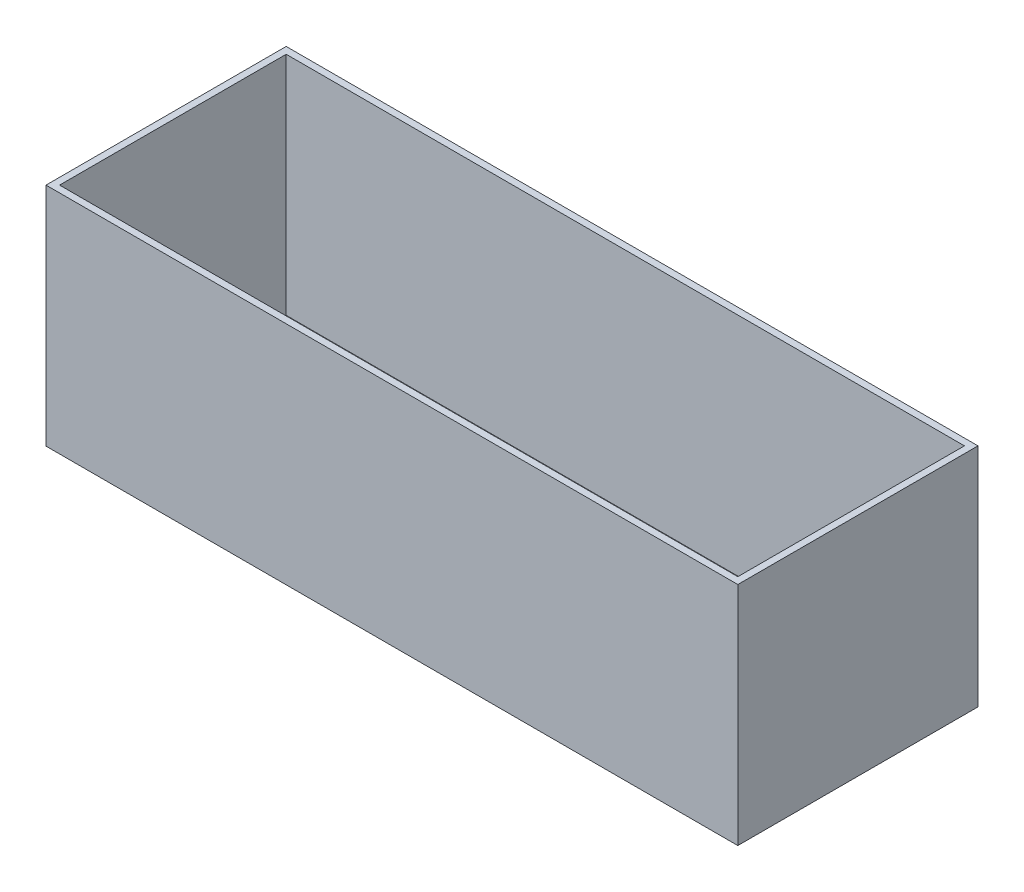
from build123d import *

# Parameters (mm, degrees)
SKETCH2_W           = 306
SKETCH2_H           = 106.24
SKETCH2_W_2         = 300
SKETCH2_H_2         = 100.24
BOSS_EXTRUDE1_DEPTH = 100


with BuildPart() as part:
    # Sketch2 → Boss-Extrude1 (new body)
    with BuildSketch(Plane(origin=(0, 0, 0), x_dir=(1, 0, 0), z_dir=(0, 1, 0))):
        with Locations((150, 50.12)):
            Rectangle(SKETCH2_W, SKETCH2_H)
        with Locations((150, 50.12)):
            Rectangle(SKETCH2_W_2, SKETCH2_H_2, mode=Mode.SUBTRACT)
    extrude(amount=BOSS_EXTRUDE1_DEPTH)


solid = part.part
